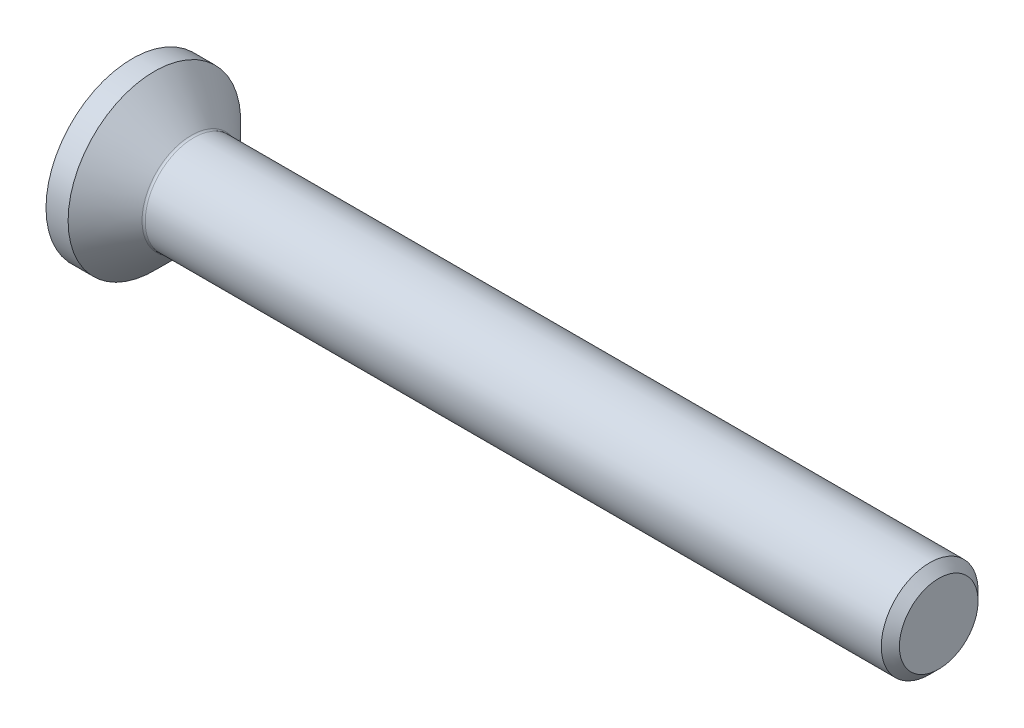
from build123d import *

# Parameters (mm, degrees)
FILLET1_R   = 0.1
HEX_2_DEPTH = 1.1


with BuildPart() as part:
    # BodySke → BaseBody (revolve)
    with BuildSketch(Plane.XY):
        Polygon((0, 0), (0, 2.675), (0.685, 2.675), (1.86, 1.5), (24.7195, 1.5), (25, 1.2195), (25, 0), align=None)
    revolve(axis=Axis((0, 0, 0), (1, 0, 0)))

    # Fillet1
    fillet1_edges = [part.edges().sort_by_distance(p)[0] for p in [
        (1.86, -1.5, 0),
    ]]
    fillet(fillet1_edges, radius=FILLET1_R)

    # Sketch2 → PreBroach (revolve, cut)
    with BuildSketch(Plane.XY):
        Polygon((0, 1), (1.1, 1), (1.677350269, 0), (0, 0), align=None)
    revolve(axis=Axis((0, 0, 0), (1, 0, 0)), mode=Mode.SUBTRACT)

    # Sketch3 → Hex 2 (cut)
    with BuildSketch(Plane.ZY):
        Polygon((-1, -0.577350269), (-1, 0.577350269), (0, 1.154700538), (1, 0.577350269), (1, -0.577350269), (0, -1.154700538), align=None)
    extrude(amount=-HEX_2_DEPTH, mode=Mode.SUBTRACT)


solid = part.part
